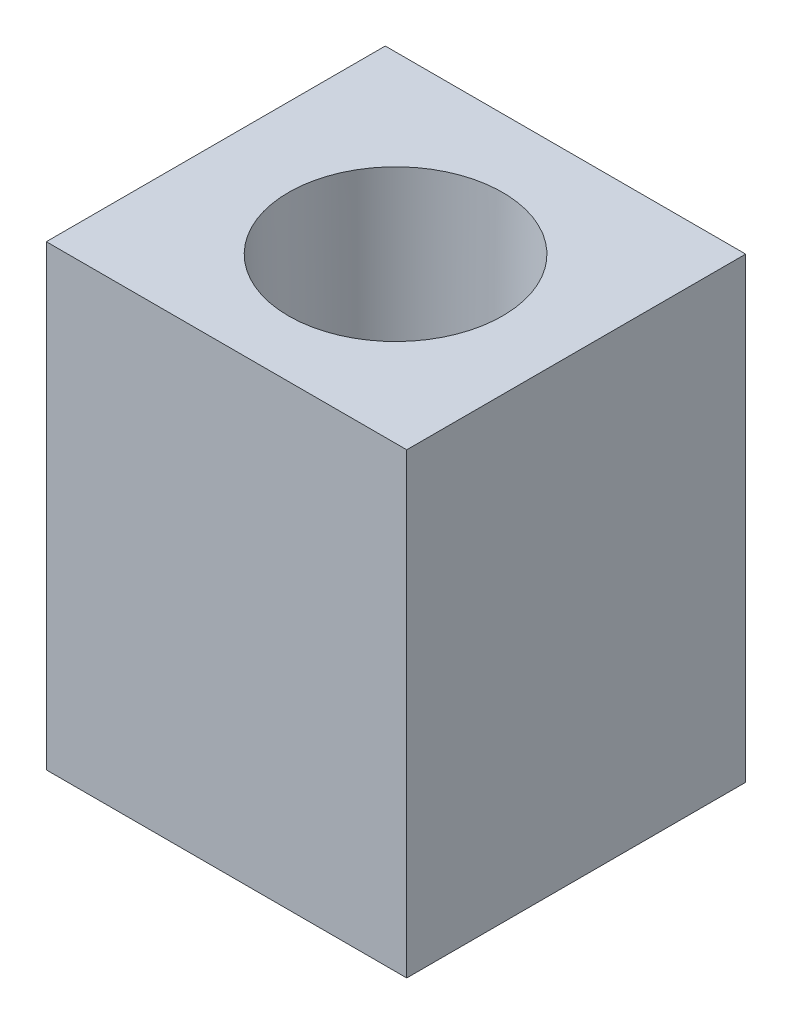
from build123d import *

# Parameters (mm, degrees)
SKETCH7_W           = 10.005786465
SKETCH7_H           = 9.409830531
BOSS_EXTRUDE2_DEPTH = 12.7
SKETCH8_R           = 2.9718
CUT_EXTRUDE1_DEPTH  = 5.588
CUT_EXTRUDE1_TAPER  = 1.05
SKETCH11_R          = 2.869383086
CUT_EXTRUDE2_DEPTH  = 8.112


with BuildPart() as part:
    # Sketch7 → Boss-Extrude2 (new body)
    with BuildSketch(Plane(origin=(0, 0, 0), x_dir=(1, 0, 0), z_dir=(0, 1, 0))):
        with Locations((-0.145137292, 0.156830508)):
            Rectangle(SKETCH7_W, SKETCH7_H)
    extrude(amount=BOSS_EXTRUDE2_DEPTH)

    # Sketch8 → Cut-Extrude1 (cut)
    with BuildSketch(Plane(origin=(0, 12.7, 0), x_dir=(1, 0, 0), z_dir=(0, 1, 0))):
        Circle(SKETCH8_R)
    extrude(amount=-CUT_EXTRUDE1_DEPTH, taper=CUT_EXTRUDE1_TAPER, mode=Mode.SUBTRACT)

    # Sketch11 → Cut-Extrude2 (cut, through all)
    with BuildSketch(Plane(origin=(0, 7.112, 0), x_dir=(1, 0, 0), z_dir=(0, 1, 0))):
        Circle(SKETCH11_R)
    extrude(amount=-CUT_EXTRUDE2_DEPTH, mode=Mode.SUBTRACT)


solid = part.part
